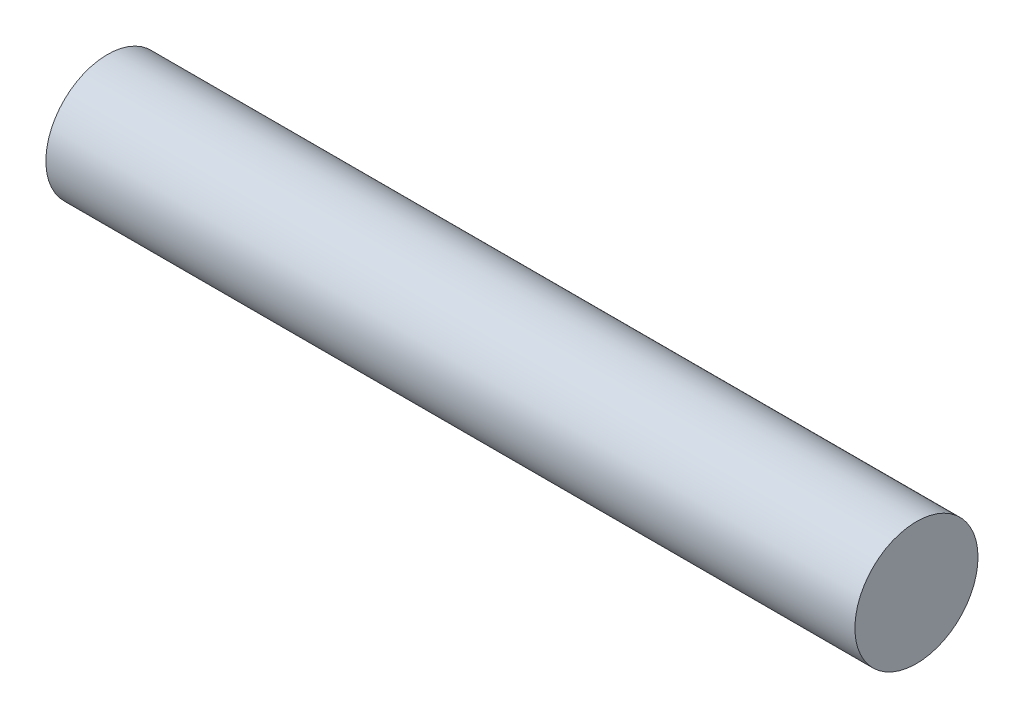
from build123d import *

# Parameters (mm, degrees)
SKETCH1_R           = 11.1125
BOSS_EXTRUDE1_DEPTH = 73.025


with BuildPart() as part:
    # Sketch1 → Boss-Extrude1 (new body, symmetric)
    with BuildSketch(Plane(origin=(0, 0, 0), x_dir=(0, 0, -1), z_dir=(1, 0, 0))):
        Circle(SKETCH1_R)
    extrude(amount=BOSS_EXTRUDE1_DEPTH, both=True)


solid = part.part
